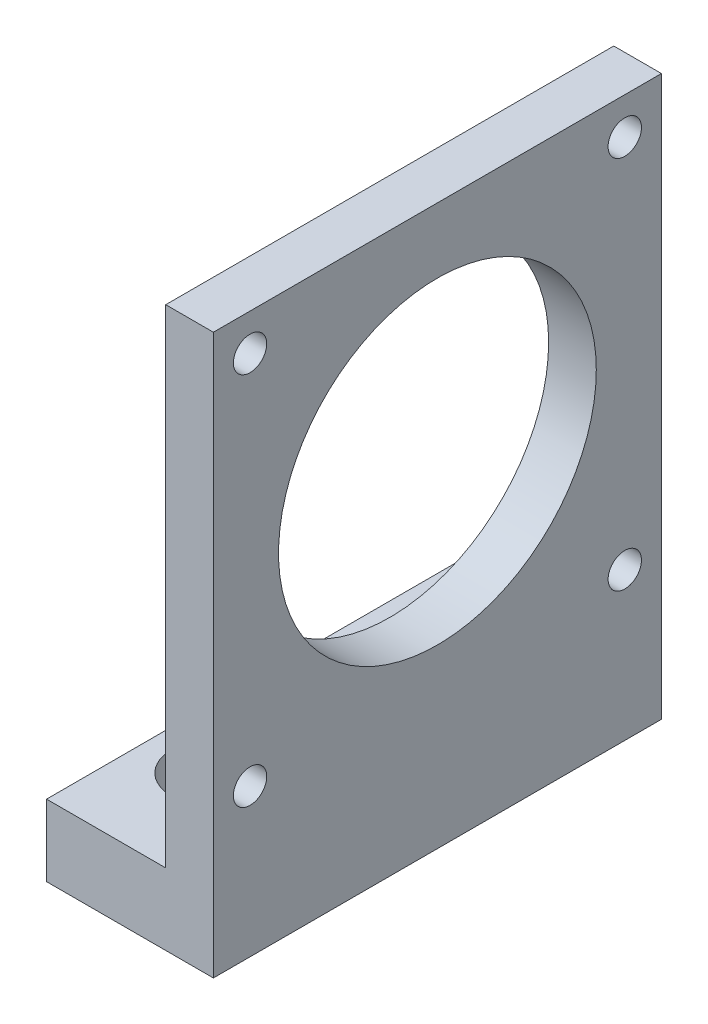
from build123d import *

# Parameters (mm, degrees)
SKETCH_1_W                     = 6
SKETCH_1_H                     = 62.4
EXTRUDE_1_DEPTH                = 56.4
SKETCH_3_W                     = 56.4
SKETCH_3_H                     = 6
EXTRUDE_3_DEPTH                = 15
HOLE_WIZARD_M5_1_D             = 4.2
HOLE_WIZARD_M5_1_DEPTH         = 12.4
HOLE_WIZARD_M5_1_TIP           = 1.2618073
SKETCH_6_R                     = 20
CUT_EXTRUDE_1_DEPTH            = 15
SKETCH_7_W                     = 21
SKETCH_7_H                     = 56.4
EXTRUDE_4_DEPTH                = 8
SKETCH_8_W                     = 15
SKETCH_8_H                     = 56.4
CUT_EXTRUDE_2_DEPTH            = 5
HOLE_WIZARD_M5_1_2_D           = 5.5
HOLE_WIZARD_M5_1_2_DEPTH       = 12.4
HOLE_WIZARD_M5_1_2_CBORE_D     = 10
HOLE_WIZARD_M5_1_2_CBORE_DEPTH = 5.4
HOLE_WIZARD_M5_1_2_TIP         = 1.652366702
SKETCH_11_W                    = 10
SKETCH_11_H                    = 30
CUT_EXTRUDE_3_DEPTH            = 5.4
SKETCH_12_W                    = 5.5
SKETCH_12_H                    = 30
CUT_EXTRUDE_4_DEPTH            = 10


with BuildPart() as part:
    # 草图1 → 凸台-拉伸1 (new body)
    with BuildSketch(Plane.XY):
        with Locations((3, 31.2)):
            Rectangle(SKETCH_1_W, SKETCH_1_H)
    extrude(amount=EXTRUDE_1_DEPTH)

    # 草图3 → 凸台-拉伸3 (add)
    with BuildSketch(Plane.ZY):
        with Locations((28.2, 3)):
            Rectangle(SKETCH_3_W, SKETCH_3_H)
    extrude(amount=EXTRUDE_3_DEPTH)

    # Hole Wizard M5 _1
    with Locations(Plane(origin=(6, 0, 0), x_dir=(0, 0, -1), z_dir=(1, 0, 0))):
        with Locations((-51.785, 57.785), (-4.615, 57.785), (-4.615, 10.615), (-51.785, 10.615)):
            Hole(HOLE_WIZARD_M5_1_D / 2, depth=HOLE_WIZARD_M5_1_DEPTH)
            with Locations((0, 0, -(HOLE_WIZARD_M5_1_DEPTH + HOLE_WIZARD_M5_1_TIP / 2))):  # 118° drill point
                Cone(0, HOLE_WIZARD_M5_1_D / 2, HOLE_WIZARD_M5_1_TIP, mode=Mode.SUBTRACT)

    # 草图6 → 切除-拉伸1 (cut)
    with BuildSketch(Plane(origin=(6, 0, 0), x_dir=(0, 0, -1), z_dir=(1, 0, 0))):
        with Locations((-28.2, 34.2)):
            Circle(SKETCH_6_R)
    extrude(amount=-CUT_EXTRUDE_1_DEPTH, mode=Mode.SUBTRACT)

    # 草图7 → 凸台-拉伸4 (add)
    with BuildSketch(Plane.XZ):
        with Locations((-4.5, 28.2)):
            Rectangle(SKETCH_7_W, SKETCH_7_H)
    extrude(amount=EXTRUDE_4_DEPTH)

    # 草图8 → 切除-拉伸2 (cut)
    with BuildSketch(Plane(origin=(0, 6, 0), x_dir=(1, 0, 0), z_dir=(0, 1, 0))):
        with Locations((-7.5, -28.2)):
            Rectangle(SKETCH_8_W, SKETCH_8_H)
    extrude(amount=-CUT_EXTRUDE_2_DEPTH, mode=Mode.SUBTRACT)

    # Hole Wizard M5 _1 2
    with Locations(Plane(origin=(0, 1, 0), x_dir=(1, 0, 0), z_dir=(0, 1, 0))):
        with Locations((-7.5, -13.2), (-7.5, -43.2)):
            CounterBoreHole(HOLE_WIZARD_M5_1_2_D / 2, HOLE_WIZARD_M5_1_2_CBORE_D / 2, HOLE_WIZARD_M5_1_2_CBORE_DEPTH, depth=HOLE_WIZARD_M5_1_2_DEPTH)
            with Locations((0, 0, -(HOLE_WIZARD_M5_1_2_DEPTH + HOLE_WIZARD_M5_1_2_TIP / 2))):  # 118° drill point
                Cone(0, HOLE_WIZARD_M5_1_2_D / 2, HOLE_WIZARD_M5_1_2_TIP, mode=Mode.SUBTRACT)

    # 草图11 → 切除-拉伸3 (cut)
    with BuildSketch(Plane(origin=(0, 1, 0), x_dir=(1, 0, 0), z_dir=(0, 1, 0))):
        with Locations((-7.5, -28.2)):
            Rectangle(SKETCH_11_W, SKETCH_11_H)
    extrude(amount=-CUT_EXTRUDE_3_DEPTH, mode=Mode.SUBTRACT)

    # 草图12 → 切除-拉伸4 (cut)
    with BuildSketch(Plane(origin=(0, -4.4, 0), x_dir=(1, 0, 0), z_dir=(0, 1, 0))):
        with Locations((-7.5, -28.2)):
            Rectangle(SKETCH_12_W, SKETCH_12_H)
    extrude(amount=-CUT_EXTRUDE_4_DEPTH, mode=Mode.SUBTRACT)


solid = part.part
